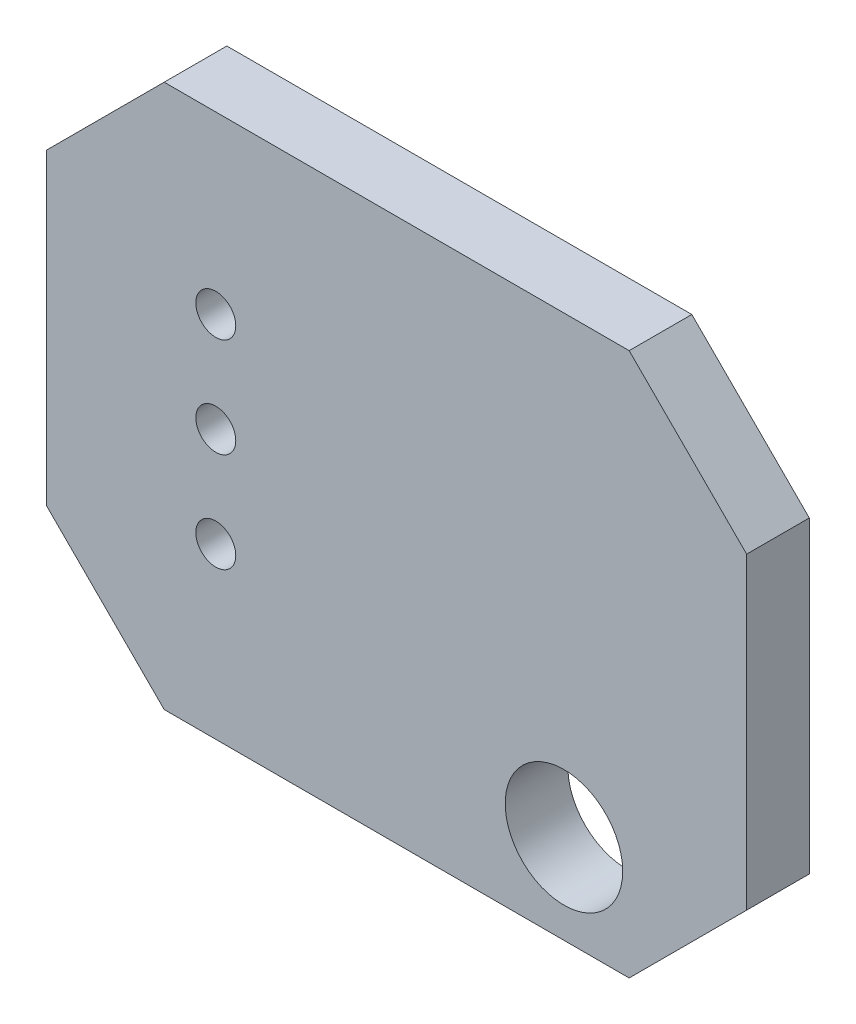
from build123d import *

# Parameters (mm, degrees)
ESQUISSE1_W         = 17.873
ESQUISSE1_H         = 13.873
BOARD_OUTLINE_DEPTH = 1.6
ESQUISSE2_R         = 1.5
NPTH_DEPTH          = 2.6
ESQUISSE3_R         = 0.51
PTH_DEPTH           = 2.6
CHANFREIN1_SIZE     = 3


with BuildPart() as part:
    # Esquisse1 → Board_Outline (new body)
    with BuildSketch(Plane.XY):
        with Locations((8.4285, 5.1585)):
            Rectangle(ESQUISSE1_W, ESQUISSE1_H)
    extrude(amount=BOARD_OUTLINE_DEPTH)

    # Esquisse2 → NPTH (cut, through all)
    with BuildSketch(Plane.XY):
        with Locations((12.7, 0.5)):
            Circle(ESQUISSE2_R)
    extrude(amount=NPTH_DEPTH, mode=Mode.SUBTRACT)

    # Esquisse3 → PTH (cut, through all)
    with BuildSketch(Plane.XY):
        with Locations((3.81, 2.54)):
            Circle(ESQUISSE3_R)
        with Locations((3.81, 5.08)):
            Circle(ESQUISSE3_R)
        with Locations((3.81, 7.62)):
            Circle(ESQUISSE3_R)
    extrude(amount=PTH_DEPTH, mode=Mode.SUBTRACT)

    # Chanfrein1
    chanfrein1_edges = [part.edges().sort_by_distance(p)[0] for p in [
        (-0.508, -1.778, 0.8),
        (-0.508, 12.095, 0.8),
        (17.365, 12.095, 0.8),
        (17.365, -1.778, 0.8),
    ]]
    chamfer(chanfrein1_edges, length=CHANFREIN1_SIZE)


solid = part.part
